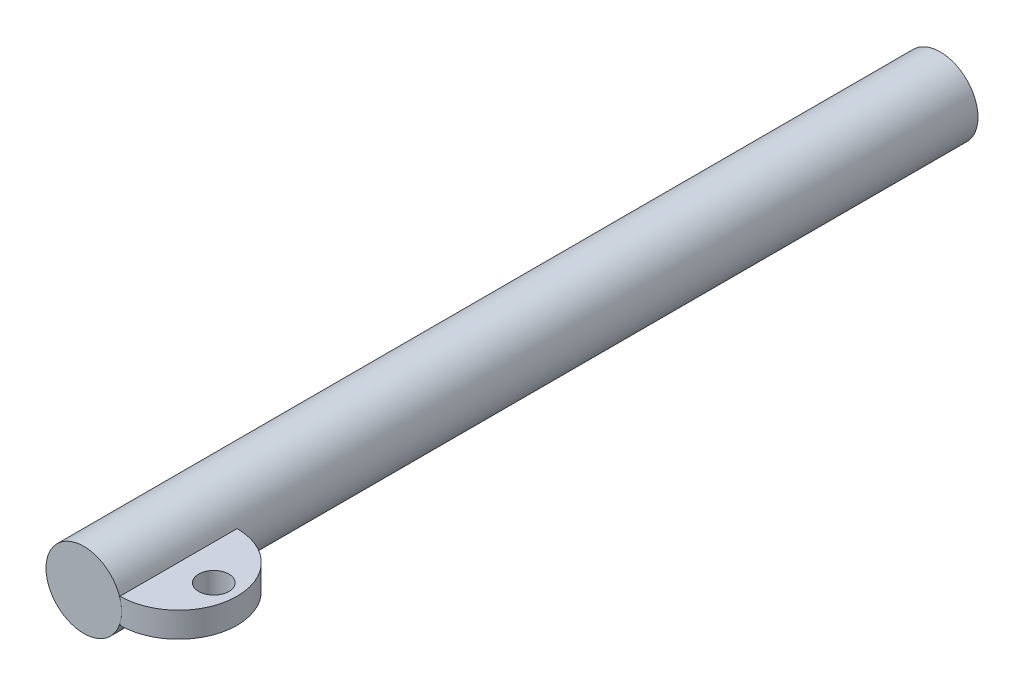
from build123d import *

# Parameters (mm, degrees)
SKETCH1_R                = 19.05
BASE_EXTRUDE_DEPTH       = 431.8
BOSS_EXTRUDE1_DEPTH      = 6.35
BOSS_EXTRUDE1_DEPTH_BACK = 6.35
SKETCH4_R                = 7.62


with BuildPart() as part:
    # Sketch1 → Base-Extrude (new body)
    with BuildSketch(Plane.XY):
        Circle(SKETCH1_R)
    extrude(amount=-BASE_EXTRUDE_DEPTH)

    # Sketch4 → Boss-Extrude1 (add, two sides: drawn at the far end of the back side and taken through both)
    with BuildSketch(Plane(origin=(0, 0, 0), x_dir=(-1, 0, 0), z_dir=(0, 1, 0)).offset(-BOSS_EXTRUDE1_DEPTH_BACK)):
        with BuildLine():
            Line((-18.231166151, -59.074644757), (-18.231166151, 0))
            ThreePointArc((-18.231166151, 0), (-47.768488529, -29.537322378), (-18.231166151, -59.074644757))
        make_face()
        with Locations((-36.011166151, -29.537322378)):
            Circle(SKETCH4_R, mode=Mode.SUBTRACT)
    extrude(amount=BOSS_EXTRUDE1_DEPTH + BOSS_EXTRUDE1_DEPTH_BACK)


solid = part.part
